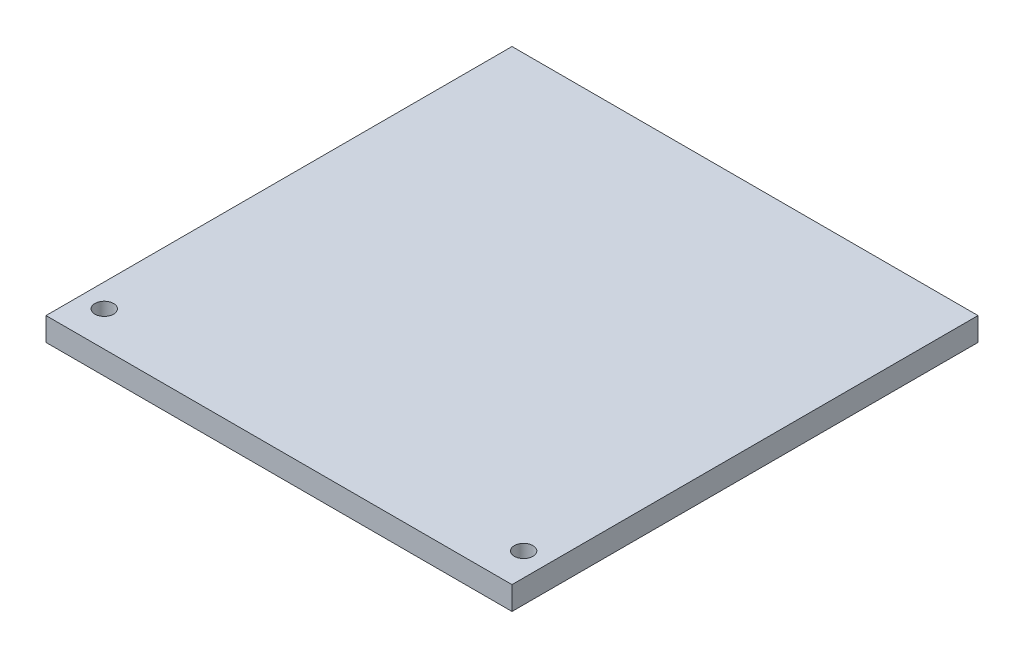
from build123d import *

# Parameters (mm, degrees)
SKETCH1_W           = 200
SKETCH1_H           = 200
BOSS_EXTRUDE1_DEPTH = 10
SKETCH2_R           = 4
CUT_EXTRUDE1_DEPTH  = 10


with BuildPart() as part:
    # Sketch1 → Boss-Extrude1 (new body)
    with BuildSketch(Plane(origin=(0, 0, 0), x_dir=(1, 0, 0), z_dir=(0, 1, 0))):
        Rectangle(SKETCH1_W, SKETCH1_H)
    extrude(amount=BOSS_EXTRUDE1_DEPTH)

    # Sketch2 → Cut-Extrude1 (cut)
    with BuildSketch(Plane(origin=(0, 10, 0), x_dir=(1, 0, 0), z_dir=(0, 1, 0))):
        with Locations((-90, -85)):
            Circle(SKETCH2_R)
        with Locations((90, -85)):
            Circle(SKETCH2_R)
    extrude(amount=-CUT_EXTRUDE1_DEPTH, mode=Mode.SUBTRACT)


solid = part.part
